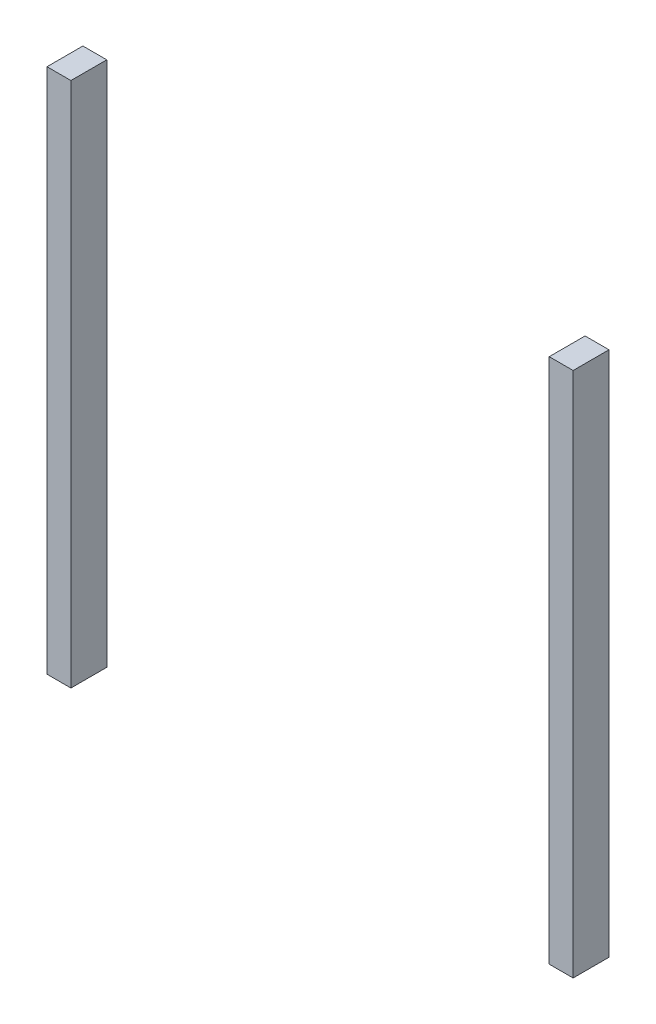
from build123d import *

# Parameters (mm, degrees)
SKETCH1_W             = 6.35
SKETCH1_H             = 139.7
BOSS_EXTRUDE1_DEPTH   = 9.525
BOSS_EXTRUDE1_2_DEPTH = 9.525


with BuildPart() as part:
    # Sketch1 → Boss-Extrude1 (new body)
    with BuildSketch(Plane.XY):
        with Locations((3.175, 69.85)):
            Rectangle(SKETCH1_W, SKETCH1_H)
    extrude(amount=BOSS_EXTRUDE1_DEPTH)


with BuildPart() as body_2:
    # Sketch1 → Boss-Extrude1 2 (new body)
    with BuildSketch(Plane.XY):
        with Locations((136.525, 69.85)):
            Rectangle(SKETCH1_W, SKETCH1_H)
    extrude(amount=BOSS_EXTRUDE1_2_DEPTH)


solid = Compound([part.part, body_2.part])
